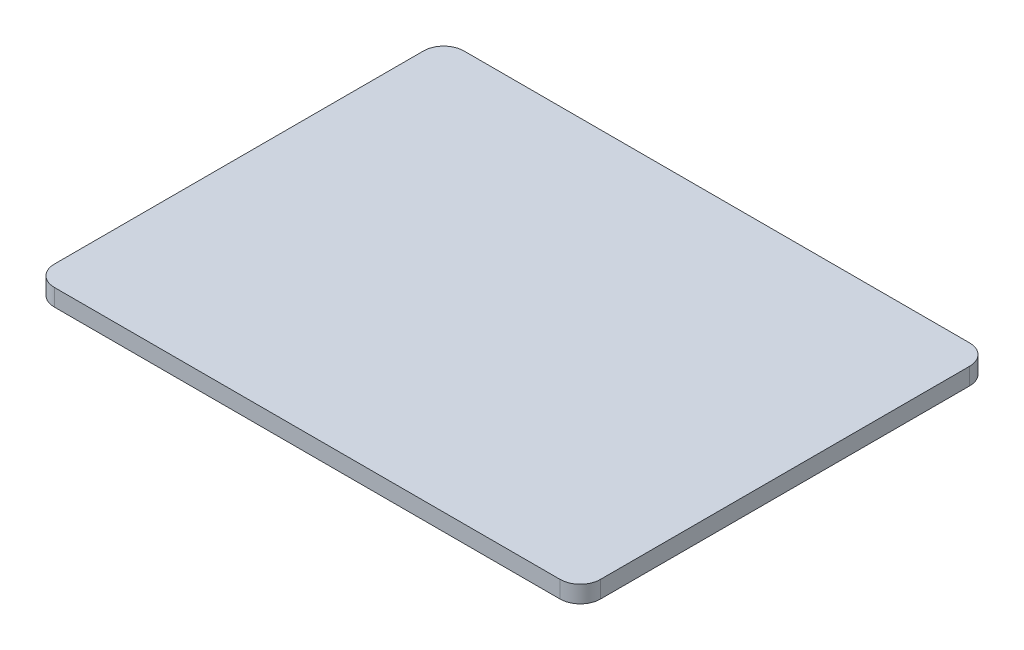
from build123d import *

# Parameters (mm, degrees)
BOSS_EXTRUDE1_DEPTH = 25.4


with BuildPart() as part:
    # Sketch1 → Boss-Extrude1 (new body)
    with BuildSketch(Plane(origin=(0, 0, 0), x_dir=(1, 0, 0), z_dir=(0, 1, 0))):
        with BuildLine():
            Line((-376.4, 304.8), (376.4, 304.8))
            ThreePointArc((376.4, 304.8), (397.613203436, 296.013203436), (406.4, 274.8))
            Line((406.4, 274.8), (406.4, -274.8))
            ThreePointArc((406.4, -274.8), (397.613203436, -296.013203436), (376.4, -304.8))
            Line((376.4, -304.8), (-376.4, -304.8))
            ThreePointArc((-376.4, -304.8), (-397.613203436, -296.013203436), (-406.4, -274.8))
            Line((-406.4, -274.8), (-406.4, 274.8))
            ThreePointArc((-406.4, 274.8), (-397.613203436, 296.013203436), (-376.4, 304.8))
        make_face()
    extrude(amount=BOSS_EXTRUDE1_DEPTH)


solid = part.part
